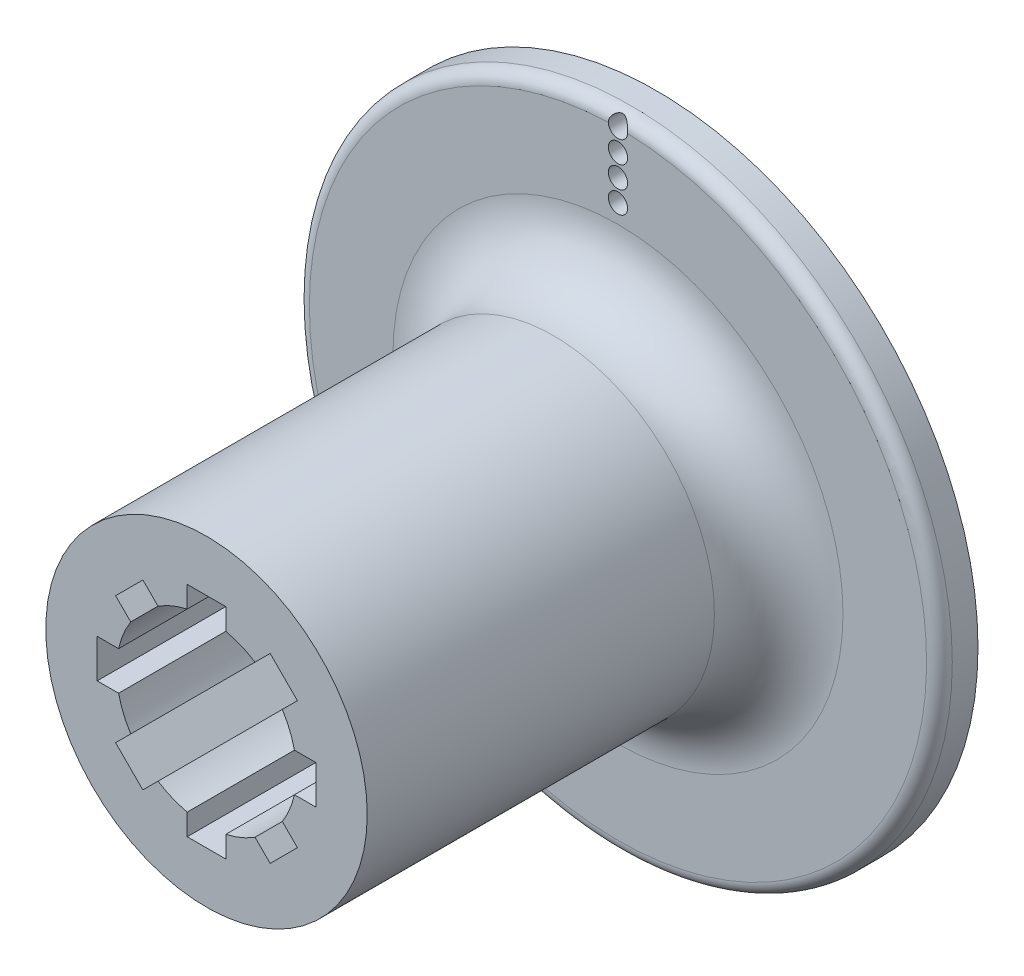
from build123d import *

# Parameters (mm, degrees)
SKETCH3_R           = 25
BOSS_EXTRUDE1_DEPTH = 70
CUT_EXTRUDE1_DEPTH  = 32
CHAMFER1_SIZE       = 1
CUT_EXTRUDE4_DEPTH  = 30
SKETCH15_R          = 2.15
CUT_EXTRUDE8_DEPTH  = 41
SKETCH16_R          = 50
SKETCH16_R_2        = 25
BOSS_EXTRUDE2_DEPTH = 6
SKETCH18_R          = 1.445
FILLET1_R           = 10
FILLET2_R           = 2
SKETCH20_R          = 1.5
CUT_EXTRUDE9_DEPTH  = 10


with BuildPart() as part:
    # Sketch3 → Boss-Extrude1 (new body)
    with BuildSketch(Plane.XY):
        Circle(SKETCH3_R)
    extrude(amount=-BOSS_EXTRUDE1_DEPTH)

    # Sketch4 → Cut-Extrude1 (cut)
    with BuildSketch(Plane(origin=(0, 0, -70), x_dir=(-1, 0, 0), z_dir=(0, 0, -1))):
        with BuildLine():
            Line((-2.55, 6.626273463), (-2.55, 9.1))
            Line((-2.55, 9.1), (2.55, 9.1))
            Line((2.55, 9.1), (2.55, 6.626273463))
            ThreePointArc((2.55, 6.626273463), (0, -7.1), (-2.55, 6.626273463))
        make_face()
    extrude(amount=-CUT_EXTRUDE1_DEPTH, mode=Mode.SUBTRACT)

    # Chamfer1
    chamfer1_edges = [part.edges().sort_by_distance(p)[0] for p in [
        (0, 9.1, -70),
        (2.55, 7.863136731, -70),
        (0, -7.1, -70),
        (-2.55, 7.863136731, -70),
    ]]
    chamfer(chamfer1_edges, length=CHAMFER1_SIZE)

    # Sketch7 → Cut-Extrude4 (cut)
    with BuildSketch(Plane.XY):
        with BuildLine():
            Line((-3, 17), (3, 17))
            Line((3, 17), (3, 13.674794331))
            ThreePointArc((3, 13.674794331), (5.357568053, 12.934313455), (7.548219459, 11.790860146))
            Line((7.548219459, 11.790860146), (9.899494937, 14.142135624))
            Line((9.899494937, 14.142135624), (14.142135624, 9.899494937))
            Line((14.142135624, 9.899494937), (11.790860146, 7.548219459))
            ThreePointArc((11.790860146, 7.548219459), (12.934313455, 5.357568053), (13.674794331, 3))
            Line((13.674794331, 3), (17, 3))
            Line((17, 3), (17, -3))
            Line((17, -3), (13.674794331, -3))
            ThreePointArc((13.674794331, -3), (12.934313455, -5.357568053), (11.790860146, -7.548219459))
            Line((11.790860146, -7.548219459), (14.142135624, -9.899494937))
            Line((14.142135624, -9.899494937), (9.899494937, -14.142135624))
            Line((9.899494937, -14.142135624), (7.548219459, -11.790860146))
            ThreePointArc((7.548219459, -11.790860146), (5.357568053, -12.934313455), (3, -13.674794331))
            Line((3, -13.674794331), (3, -17))
            Line((3, -17), (-3, -17))
            Line((-3, -17), (-3, -13.674794331))
            ThreePointArc((-3, -13.674794331), (-5.357568053, -12.934313455), (-7.548219459, -11.790860146))
            Line((-7.548219459, -11.790860146), (-9.899494937, -14.142135624))
            Line((-9.899494937, -14.142135624), (-14.142135624, -9.899494937))
            Line((-14.142135624, -9.899494937), (-11.790860146, -7.548219459))
            ThreePointArc((-11.790860146, -7.548219459), (-12.934313455, -5.357568053), (-13.674794331, -3))
            Line((-13.674794331, -3), (-17, -3))
            Line((-17, -3), (-17, 3))
            Line((-17, 3), (-13.674794331, 3))
            ThreePointArc((-13.674794331, 3), (-12.934313455, 5.357568053), (-11.790860146, 7.548219459))
            Line((-11.790860146, 7.548219459), (-14.142135624, 9.899494937))
            Line((-14.142135624, 9.899494937), (-9.899494937, 14.142135624))
            Line((-9.899494937, 14.142135624), (-7.548219459, 11.790860146))
            ThreePointArc((-7.548219459, 11.790860146), (-5.357568053, 12.934313455), (-3, 13.674794331))
            Line((-3, 13.674794331), (-3, 17))
        make_face()
    extrude(amount=-CUT_EXTRUDE4_DEPTH, mode=Mode.SUBTRACT)

    # Sketch15 → Cut-Extrude8 (cut, through all)
    with BuildSketch(Plane.XY.offset(-30)):
        Circle(SKETCH15_R)
    extrude(amount=-CUT_EXTRUDE8_DEPTH, mode=Mode.SUBTRACT)

    # Sketch16 → Boss-Extrude2 (add)
    with BuildSketch(Plane(origin=(0, 0, -70), x_dir=(-1, 0, 0), z_dir=(0, 0, -1))):
        Circle(SKETCH16_R)
        Circle(SKETCH16_R_2, mode=Mode.SUBTRACT)
    extrude(amount=-BOSS_EXTRUDE2_DEPTH)

    # Cut-Sweep1: sweep along a path in Sketch19
    with BuildLine(Plane(origin=(0, 0, -70), x_dir=(-1, 0, 0), z_dir=(0, 0, -1))) as cut_sweep1_path:
        CenterArc((0, 0), 37.885, 0, 360)
    # Sketch18 → Cut-Sweep1 (sweep, cut)
    with BuildSketch(Plane(origin=(0, 0, 0), x_dir=(0, 0, -1), z_dir=(1, 0, 0))):
        with Locations((69.2, 48.055)):
            Circle(SKETCH18_R)
        with Locations((69.2, 44.665)):
            Circle(SKETCH18_R)
        with Locations((69.2, 41.275)):
            Circle(SKETCH18_R)
        with Locations((69.2, 37.885)):
            Circle(SKETCH18_R)
    sweep(path=cut_sweep1_path.line, mode=Mode.SUBTRACT)

    # Fillet1
    fillet1_edges = [part.edges().sort_by_distance(p)[0] for p in [
        (-25, 0, -64),
    ]]
    fillet(fillet1_edges, radius=FILLET1_R)

    # Fillet2
    fillet2_edges = [part.edges().sort_by_distance(p)[0] for p in [
        (50, 0, -64),
    ]]
    fillet(fillet2_edges, radius=FILLET2_R)

    # Sketch20 → Cut-Extrude9 (cut)
    with BuildSketch(Plane(origin=(0, 0, -70), x_dir=(-1, 0, 0), z_dir=(0, 0, -1))):
        with Locations((0, 48.055)):
            Circle(SKETCH20_R)
        with Locations((0, 44.665)):
            Circle(SKETCH20_R)
        with Locations((0, 41.275)):
            Circle(SKETCH20_R)
        with Locations((0, 37.885)):
            Circle(SKETCH20_R)
    extrude(amount=-CUT_EXTRUDE9_DEPTH, mode=Mode.SUBTRACT)


solid = part.part
